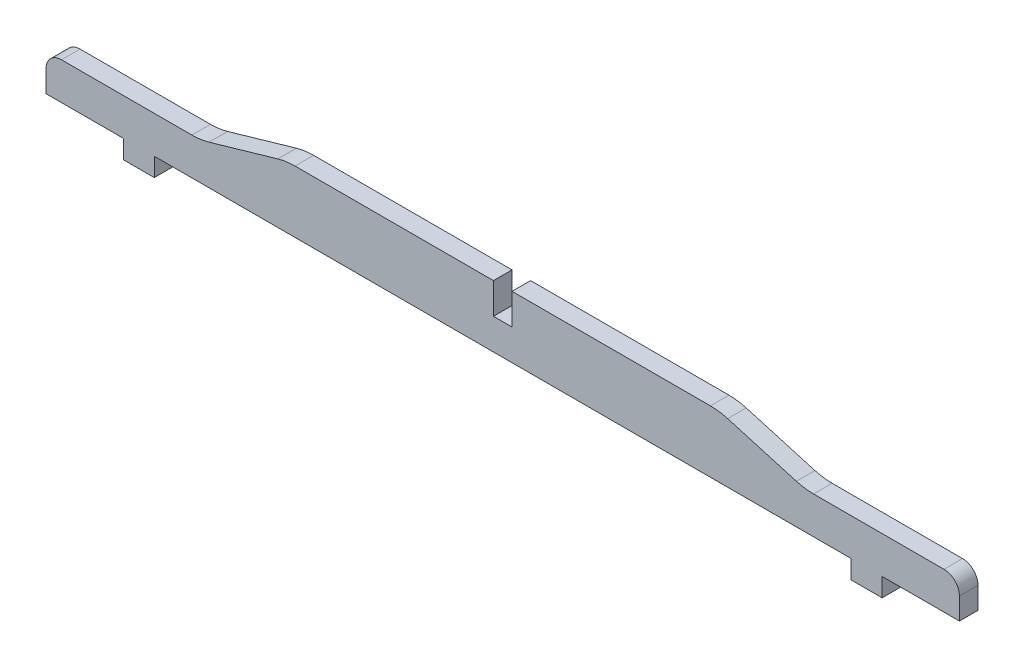
from build123d import *

# Parameters (mm, degrees)
BOSS_EXTRUDE1_DEPTH     = 6
FILLET1_R               = 5
FILLET2_R               = 20
SKETCH2_W               = 6
SKETCH2_H               = 10
CUT_EXTRUDE1_DEPTH      = 1
CUT_EXTRUDE1_DEPTH_BACK = 7


with BuildPart() as part:
    # Sketch1 → Boss-Extrude1 (new body)
    with BuildSketch(Plane.XY):
        Polygon((70, 0), (-70, 0), (-97.66666667, -8), (-147.66666667, -8), (-147.66666667, -20), (-122.66666667, -20), (-122.66666667, -26), (-112.66666667, -26), (-112.66666667, -20), (112.66666667, -20), (112.66666667, -26), (122.66666667, -26), (122.66666667, -20), (147.66666667, -20), (147.66666667, -8), (97.66666667, -8), align=None)
    extrude(amount=BOSS_EXTRUDE1_DEPTH)

    # Fillet1
    fillet1_edges = [part.edges().sort_by_distance(p)[0] for p in [
        (-147.66666667, -8, 3),
        (147.66666667, -8, 3),
    ]]
    fillet(fillet1_edges, radius=FILLET1_R)

    # Fillet2
    fillet2_edges = [part.edges().sort_by_distance(p)[0] for p in [
        (-97.66666667, -8, 3),
        (-70, 0, 3),
        (70, 0, 3),
        (97.66666667, -8, 3),
    ]]
    fillet(fillet2_edges, radius=FILLET2_R)

    # Sketch2 → Cut-Extrude1 (cut, two sides)
    with BuildSketch(Plane.XY.offset(6)) as cut_extrude1_sk:
        with Locations((0, -5)):
            Rectangle(SKETCH2_W, SKETCH2_H)
    extrude(amount=CUT_EXTRUDE1_DEPTH, mode=Mode.SUBTRACT)
    extrude(cut_extrude1_sk.sketch, amount=-CUT_EXTRUDE1_DEPTH_BACK, mode=Mode.SUBTRACT)


solid = part.part
